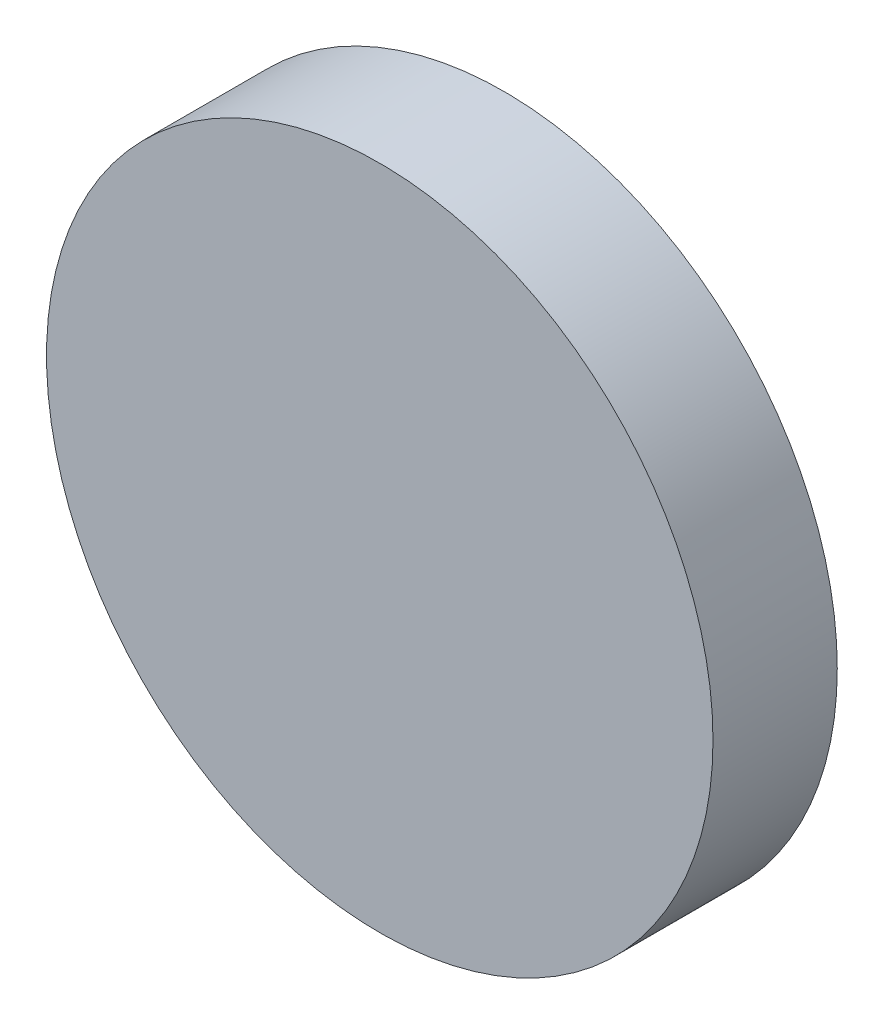
from build123d import *

# Parameters (mm, degrees)
SKETCH1_R           = 39.95
BOSS_EXTRUDE1_DEPTH = 14.9


with BuildPart() as part:
    # Sketch1 → Boss-Extrude1 (new body)
    with BuildSketch(Plane.XY):
        Circle(SKETCH1_R)
    extrude(amount=BOSS_EXTRUDE1_DEPTH)


solid = part.part
